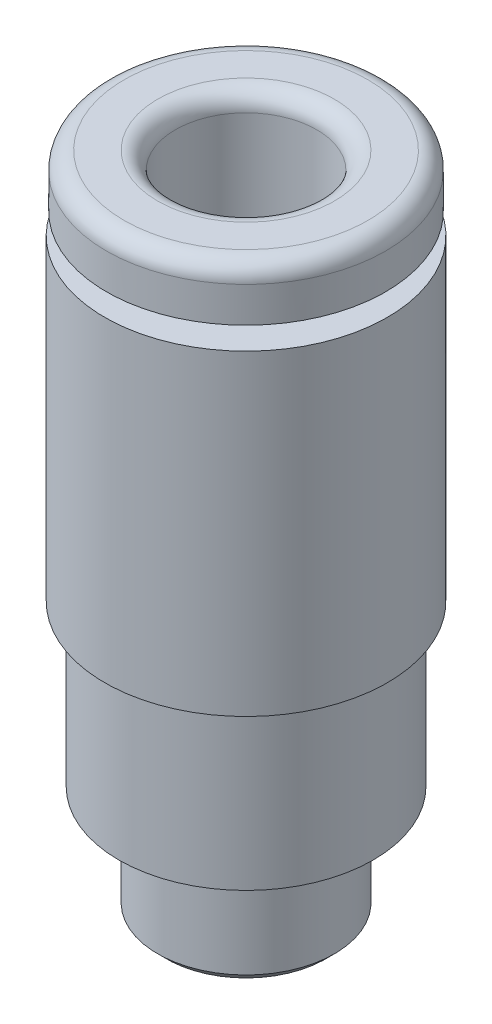
from build123d import *

# Parameters (mm, degrees)
SKETCH2_R                 = 2.5
BOSS_EXTRUDE1_DEPTH       = 3.1
CUT_EXTRUDE1_DEPTH        = 14.7
CUT_EXTRUDE1_TAPER        = 2
SKETCH4_W                 = 2
SKETCH4_H                 = 12.7
F_2_CLEARANCE_HOLE1_D     = 2.360316922
F_2_CLEARANCE_HOLE1_DEPTH = 18.7
CHAMFER1_SIZE             = 0.25
FILLET1_R                 = 0.5


with BuildPart() as part:
    # Sketch1 → Revolve1 (revolve)
    with BuildSketch(Plane.XY):
        Polygon((3.95, 0), (0, 0), (0, -15.6), (3.6, -15.6), (3.6, -11.2), (4, -11.054411906), (4, -2.1), (2.2, -2.1), (2.2, -1.5), (3.95, -1.5), align=None)
    revolve(axis=Axis((0, 0, 0), (0, -1, 0)))

    # Sketch2 → Boss-Extrude1 (add)
    with BuildSketch(Plane.XZ.offset(15.6)):
        Circle(SKETCH2_R)
    extrude(amount=BOSS_EXTRUDE1_DEPTH)

    # Sketch3 → Cut-Extrude1 (cut)
    with BuildSketch(Plane(origin=(0, 0, 0), x_dir=(-1, 0, 0), z_dir=(0, 1, 0))):
        Polygon((0.977739085, -1.693493773), (1.955478171, 0), (0.977739085, 1.693493773), (-0.977739085, 1.693493773), (-1.955478171, 0), (-0.977739085, -1.693493773), align=None)
    extrude(amount=-CUT_EXTRUDE1_DEPTH, taper=CUT_EXTRUDE1_TAPER, mode=Mode.SUBTRACT)

    # Sketch4 → Cut-Revolve1 (revolve, cut)
    with BuildSketch(Plane(origin=(0, 0, 0), x_dir=(0, 0, -1), z_dir=(1, 0, 0))):
        with Locations((-1, -6.35)):
            Rectangle(SKETCH4_W, SKETCH4_H)
    revolve(axis=Axis((0, -12.7, 0), (0, 1, 0)), mode=Mode.SUBTRACT)

    # #2 Clearance Hole1
    with Locations(Plane(origin=(0, -18.7, 0), x_dir=(-1, 0, 0), z_dir=(0, -1, 0))):
        with Locations((0, 0)):
            Hole(F_2_CLEARANCE_HOLE1_D / 2, depth=F_2_CLEARANCE_HOLE1_DEPTH)

    # Chamfer1
    chamfer1_edges = [part.edges().sort_by_distance(p)[0] for p in [
        (-2.5, -18.7, 0),
    ]]
    chamfer(chamfer1_edges, length=CHAMFER1_SIZE)

    # Fillet1
    fillet1_edges = [part.edges().sort_by_distance(p)[0] for p in [
        (-3.95, 0, 0),
        (0, 0, -2),
    ]]
    fillet(fillet1_edges, radius=FILLET1_R)


solid = part.part
